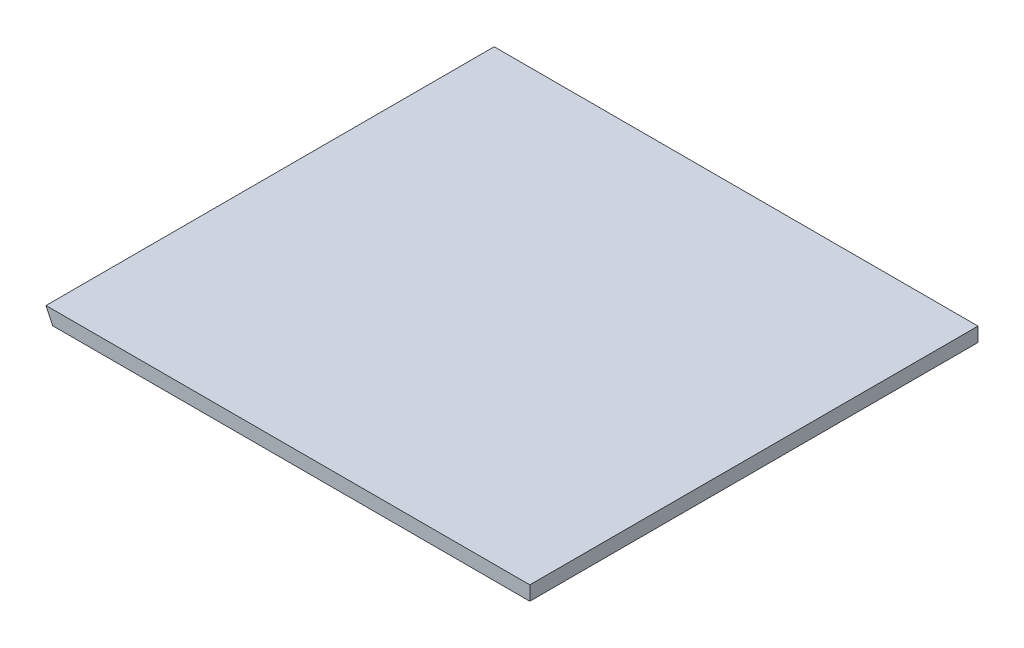
from build123d import *

# Parameters (mm, degrees)
BOSS_EXTRUDE1_DEPTH = 400


with BuildPart() as part:
    # Sketch1 → Boss-Extrude1 (new body)
    with BuildSketch(Plane.XY):
        Polygon((-438.52128764, 22.225), (-444.515119941, 34.925), (-12.7, 34.925), (-12.7, 22.225), align=None)
    extrude(amount=BOSS_EXTRUDE1_DEPTH)


solid = part.part
